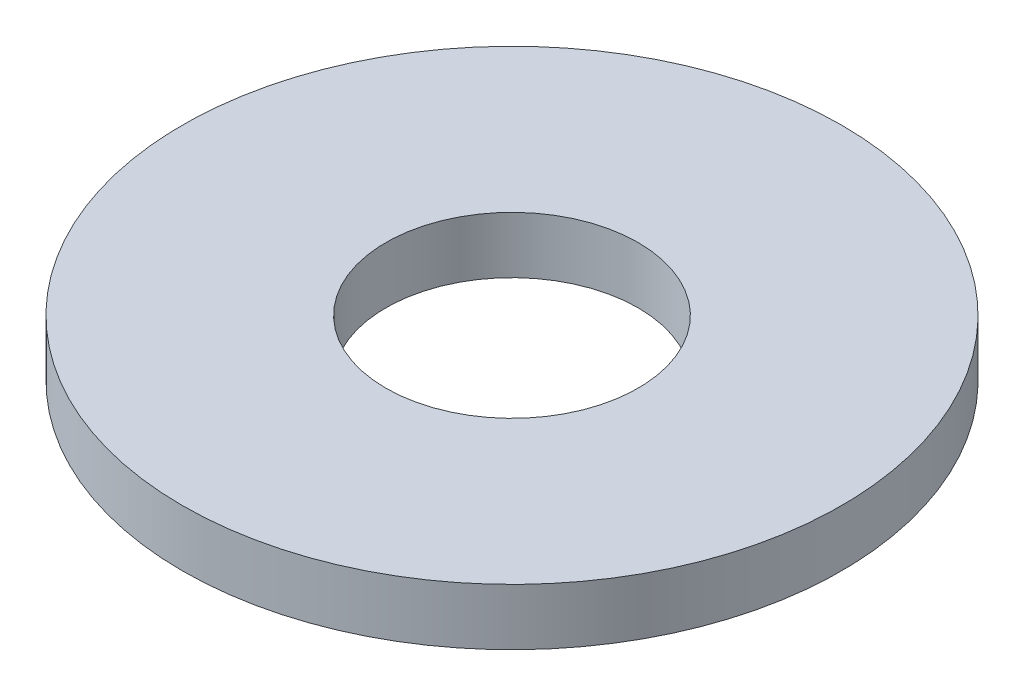
from build123d import *

# Parameters (mm, degrees)
ESQUISSE1_R        = 9.3218
ESQUISSE1_R_2      = 3.5687
BOSS_EXTRU_1_DEPTH = 1.6002


with BuildPart() as part:
    # Esquisse1 → Boss.-Extru.1 (new body)
    with BuildSketch(Plane(origin=(0, 0, 0), x_dir=(1, 0, 0), z_dir=(0, 1, 0))):
        with Locations(Location((0, 0, 0), (0, 0, 270))):  # turned: the seam where the file's is
            Circle(ESQUISSE1_R)
        with Locations(Location((0, 0, 0), (0, 0, 270))):  # turned: the seam where the file's is
            Circle(ESQUISSE1_R_2, mode=Mode.SUBTRACT)
    extrude(amount=BOSS_EXTRU_1_DEPTH)


solid = part.part
